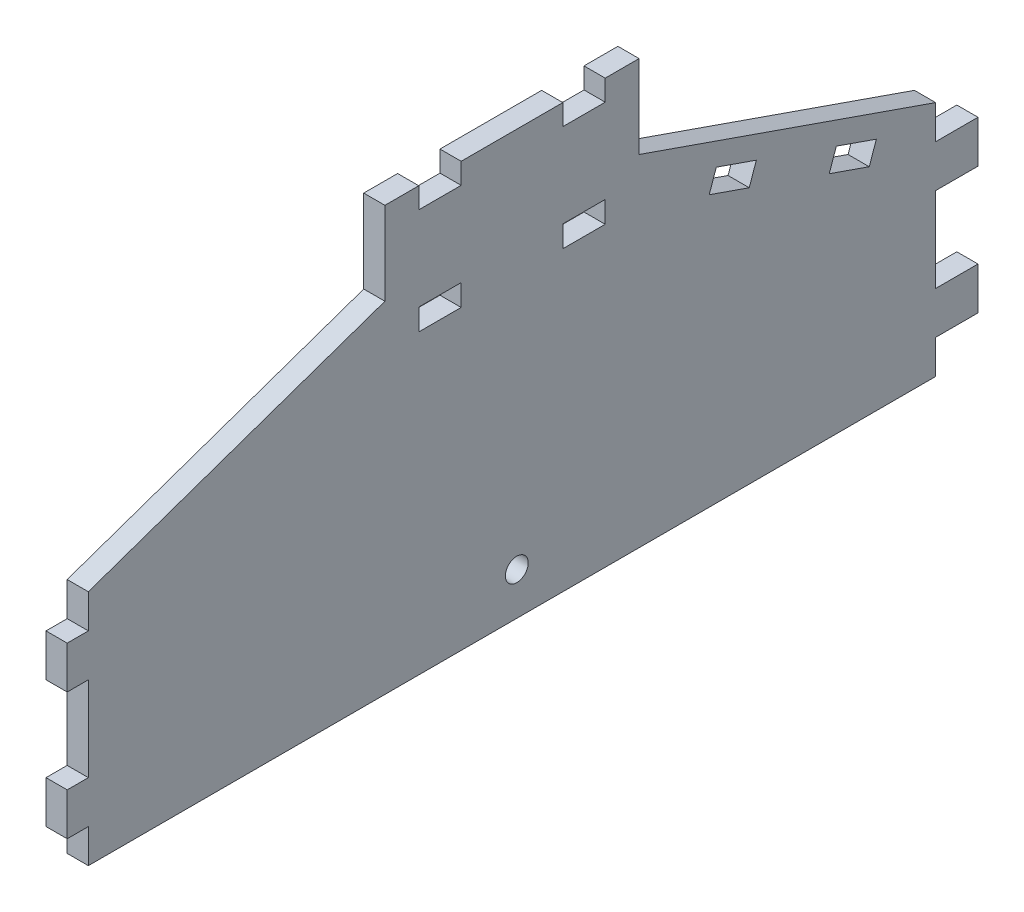
from build123d import *

# Parameters (mm, degrees)
SKETCH1_W                      = 38.1
SKETCH1_H                      = 63.5
BOSS_EXTRUDE1_DEPTH            = 3.175
SKETCH2_W                      = 6.35
SKETCH2_H                      = 3.1242
CUT_EXTRUDE1_DEPTH             = 4.175
SKETCH3_W                      = 6.35
SKETCH3_H                      = 3.2258
CUT_FOR_TABS_SERVO_PLATE_DEPTH = 4.175
BASE_EXTENSION_DEPTH           = 3.175
SKETCH5_W                      = 6.35
SKETCH5_H                      = 6.35
SKETCH5_W_2                    = 3.175
TABS_DEPTH                     = 3.175
CUT_FOR_NECK_COVER_TABS_DEPTH  = 4.175
SKETCH7_R                      = 1.7145
CUT_EXTRUDE2_DEPTH             = 4.175


with BuildPart() as part:
    # Sketch1 → Boss-Extrude1 (new body)
    with BuildSketch(Plane(origin=(0, 0, 0), x_dir=(0, 0, -1), z_dir=(1, 0, 0))):
        Rectangle(SKETCH1_W, SKETCH1_H)
    extrude(amount=BOSS_EXTRUDE1_DEPTH)

    # Sketch2 → Cut-Extrude1 (cut, through all)
    with BuildSketch(Plane.ZY):
        with Locations((-10.795, 30.1879)):
            Rectangle(SKETCH2_W, SKETCH2_H)
        with Locations((10.795, 30.1879)):
            Rectangle(SKETCH2_W, SKETCH2_H)
    extrude(amount=-CUT_EXTRUDE1_DEPTH, mode=Mode.SUBTRACT)

    # Sketch3 → cut for tabs servo plate (cut, through all)
    with BuildSketch(Plane.ZY):
        with Locations((-10.795, 14.3891)):
            Rectangle(SKETCH3_W, SKETCH3_H)
        with Locations((10.795, 14.3891)):
            Rectangle(SKETCH3_W, SKETCH3_H)
    extrude(amount=-CUT_FOR_TABS_SERVO_PLATE_DEPTH, mode=Mode.SUBTRACT)

    # Sketch4 → base extension (add)
    with BuildSketch(Plane.ZY):
        Polygon((19.05, -31.75), (63.5, -31.75), (63.5, 3.81), (19.05, 19.295607145), align=None)
    base_extension = extrude(amount=-BASE_EXTENSION_DEPTH)

    # Mirror1: base extension across plane
    add(base_extension.mirror(Plane.XY))

    # Sketch5 → tabs (add)
    with BuildSketch(Plane(origin=(3.175, 0, 0), x_dir=(0, 0, -1), z_dir=(1, 0, 0))):
        with Locations((66.675, -4.445)):
            Rectangle(SKETCH5_W, SKETCH5_H)
        with Locations((66.675, -23.495)):
            Rectangle(SKETCH5_W, SKETCH5_H)
        with Locations((-65.0875, -4.445)):
            Rectangle(SKETCH5_W_2, SKETCH5_H)
        with Locations((-65.0875, -23.495)):
            Rectangle(SKETCH5_W_2, SKETCH5_H)
    extrude(amount=-TABS_DEPTH)

    # Sketch6 → cut for neck cover tabs (cut, through all)
    with BuildSketch(Plane.ZY):
        Polygon((-36.620444722, 9.771864523), (-30.623926297, 11.860947281), (-29.562672256, 8.814715921), (-35.559190682, 6.725633163), align=None)
        Polygon((-48.613481574, 5.593699008), (-47.552227533, 2.547467647), (-53.548745959, 0.45838489), (-54.61, 3.50461625), align=None)
    extrude(amount=-CUT_FOR_NECK_COVER_TABS_DEPTH, mode=Mode.SUBTRACT)

    # Sketch7 → Cut-Extrude2 (cut, through all)
    with BuildSketch(Plane.ZY):
        with Locations((-0.718022777, -25.4)):
            Circle(SKETCH7_R)
    extrude(amount=-CUT_EXTRUDE2_DEPTH, mode=Mode.SUBTRACT)


solid = part.part
